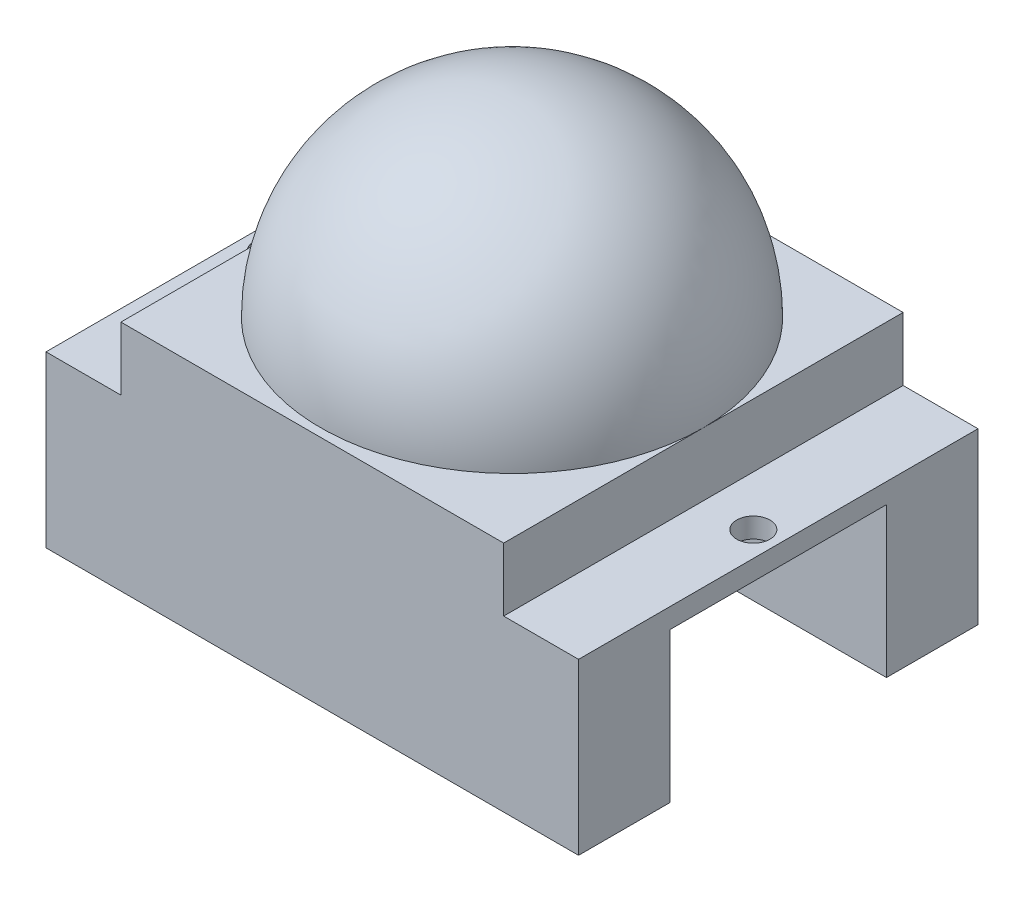
from build123d import *

# Parameters (mm, degrees)
SKETCH_1_W          = 32
SKETCH_1_H          = 24
EXTRUDE_1_DEPTH     = 1.2
SKETCH_2_W          = 23
SKETCH_2_H          = 24
EXTRUDE_2_DEPTH     = 5
SKETCH_6_W          = 32
SKETCH_6_H          = 5.5
EXTRUDE_5_DEPTH     = 9
SKETCH_8_R          = 1
CUT_EXTRUDE_7_DEPTH = 10


with BuildPart() as part:
    # 草图1 → 凸台-拉伸1 (new body)
    with BuildSketch(Plane(origin=(0, 0, 0), x_dir=(1, 0, 0), z_dir=(0, 1, 0))):
        Rectangle(SKETCH_1_W, SKETCH_1_H)
    extrude(amount=EXTRUDE_1_DEPTH)

    # 草图2 → 凸台-拉伸2 (add)
    with BuildSketch(Plane(origin=(0, 0, 0), x_dir=(1, 0, 0), z_dir=(0, 1, 0))):
        Rectangle(SKETCH_2_W, SKETCH_2_H)
    extrude(amount=EXTRUDE_2_DEPTH)

    # 草图5 → 旋转5 (revolve)
    with BuildSketch(Plane.XY):
        with BuildLine():
            Line((0, 5), (11.5, 5))
            ThreePointArc((11.5, 5), (8.131727984, 13.131727984), (0, 16.5))
            Line((0, 16.5), (0, 5))
        make_face()
    revolve(axis=Axis((0, 5, 0), (0, 1, 0)))

    # 草图6 → 凸台-拉伸5 (add)
    with BuildSketch(Plane(origin=(0, 0, 0), x_dir=(1, 0, 0), z_dir=(0, 1, 0))):
        with Locations((0, 9.25)):
            Rectangle(SKETCH_6_W, SKETCH_6_H)
        with Locations((0, -9.25)):
            Rectangle(SKETCH_6_W, SKETCH_6_H)
    extrude(amount=-EXTRUDE_5_DEPTH)

    # 草图8 → 切除-拉伸7 (cut)
    with BuildSketch(Plane(origin=(0, 0, 0), x_dir=(1, 0, 0), z_dir=(0, 1, 0))):
        with Locations((14.5, 0)):
            Circle(SKETCH_8_R)
        with Locations((-14.5, 0)):
            Circle(SKETCH_8_R)
    extrude(amount=CUT_EXTRUDE_7_DEPTH, mode=Mode.SUBTRACT)


solid = part.part
